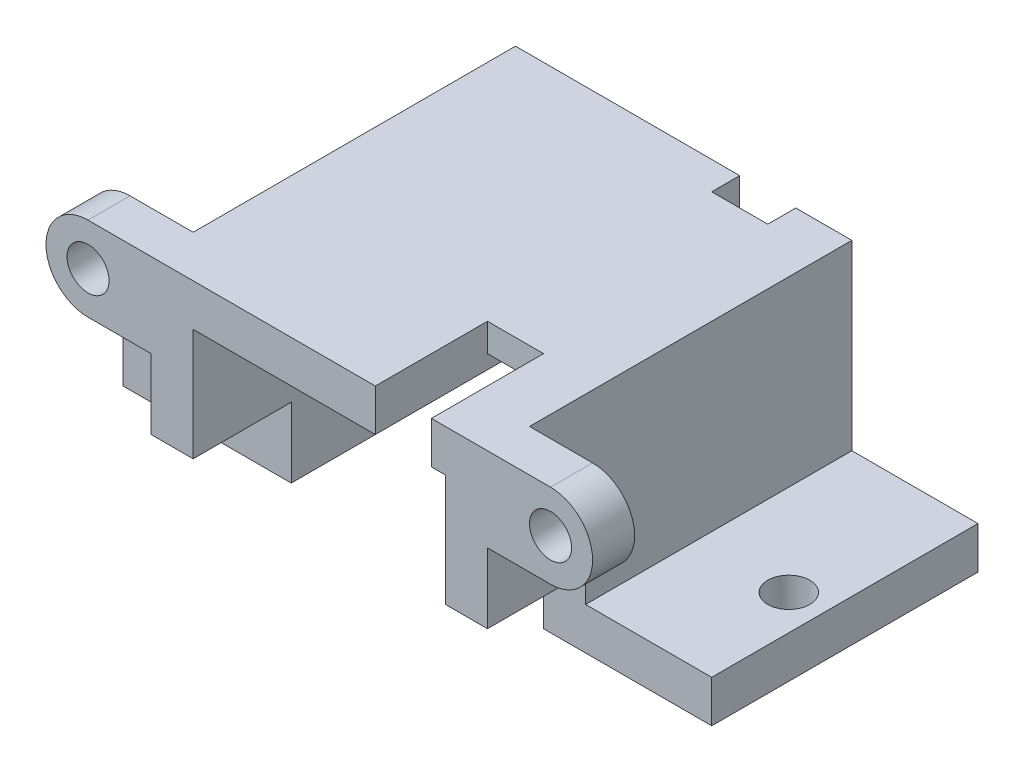
from build123d import *

# Parameters (mm, degrees)
EXTRU_MINCE1_DEPTH      = 13
EXTRUSION1_DEPTH        = 3
ESQUISSE3_R             = 1.5
ENL_V_MAT_EXTRU_1_DEPTH = 3
ENL_V_MAT_EXTRU_2_REACH = 18
ESQUISSE4_W             = 4
ESQUISSE4_H             = 8
ESQUISSE4_H_2           = 2
ESQUISSE6_W             = 7
ESQUISSE6_H             = 5
ENL_V_MAT_EXTRU_4_DEPTH = 42
ESQUISSE7_R             = 1.5
ENL_V_MAT_EXTRU_5_DEPTH = 3
ESQUISSE8_W             = 4
ESQUISSE8_H             = 16
ENL_V_MAT_EXTRU_6_DEPTH = 1


with BuildPart() as part:
    # Esquisse1 → Extru.-Mince1 (new body, symmetric)
    with BuildSketch(Plane.XY):
        Polygon((-21, 0), (-9, 0), (-9, 13), (9, 13), (9, 0), (21, 0), (21, 3), (12, 3), (12, 16), (-12, 16), (-12, 3), (-21, 3), align=None)
    extrude(amount=EXTRU_MINCE1_DEPTH, both=True)

    # Esquisse2 → Extrusion1 (add)
    with BuildSketch(Plane.XY.offset(13)):
        with BuildLine():
            Line((-12, 16), (-16.5, 16))
            ThreePointArc((-16.5, 16), (-19.5, 13), (-16.5, 10))
            Line((-16.5, 10), (-12, 10))
            Line((-12, 10), (-12, 16))
        make_face()
    extrusion1 = extrude(amount=-EXTRUSION1_DEPTH)

    # Esquisse3 → Enlèv. mat.-Extru.1 (cut)
    with BuildSketch(Plane.XY.offset(13)):
        with Locations((-16.5, 13)):
            Circle(ESQUISSE3_R)
    enl_v_mat_extru_1 = extrude(amount=-ENL_V_MAT_EXTRU_1_DEPTH, mode=Mode.SUBTRACT)

    # Symétrie1: Extrusion1, Enlèv. mat.-Extru.1 across plane
    add(extrusion1.mirror(Plane(origin=(0, 0, 0), x_dir=(0, 0, 1), z_dir=(1, 0, 0))))
    add(enl_v_mat_extru_1.mirror(Plane(origin=(0, 0, 0), x_dir=(0, 0, 1), z_dir=(1, 0, 0))), mode=Mode.SUBTRACT)

    # Esquisse4 → Enlèv. mat.-Extru.2 (cut, up to next)
    with BuildSketch(Plane(origin=(0, 16, 0), x_dir=(1, 0, 0), z_dir=(0, 1, 0)), mode=Mode.PRIVATE) as enl_v_mat_extru_2_sk1:
        with Locations((6, -9)):
            Rectangle(ESQUISSE4_W, ESQUISSE4_H)
    enl_v_mat_extru_2_tool1 = extrude(enl_v_mat_extru_2_sk1.sketch, amount=-ENL_V_MAT_EXTRU_2_REACH, mode=Mode.PRIVATE) & part.part
    add(enl_v_mat_extru_2_tool1.solids().sort_by_distance((6, 16, 9))[0], mode=Mode.SUBTRACT)
    # Esquisse4 → Enlèv. mat.-Extru.2 (cut, up to next)
    with BuildSketch(Plane(origin=(0, 16, 0), x_dir=(1, 0, 0), z_dir=(0, 1, 0)), mode=Mode.PRIVATE) as enl_v_mat_extru_2_sk2:
        with Locations((6, 12)):
            Rectangle(ESQUISSE4_W, ESQUISSE4_H_2)
    enl_v_mat_extru_2_tool2 = extrude(enl_v_mat_extru_2_sk2.sketch, amount=-ENL_V_MAT_EXTRU_2_REACH, mode=Mode.PRIVATE) & part.part
    add(enl_v_mat_extru_2_tool2.solids().sort_by_distance((6, 16, -12))[0], mode=Mode.SUBTRACT)

    # Esquisse6 → Enlèv. mat.-Extru.4 (cut)
    with BuildSketch(Plane(origin=(21, 0, 0), x_dir=(0, 0, -1), z_dir=(1, 0, 0))):
        with Locations((-9.5, 2.5)):
            Rectangle(ESQUISSE6_W, ESQUISSE6_H)
    extrude(amount=-ENL_V_MAT_EXTRU_4_DEPTH, mode=Mode.SUBTRACT)

    # Esquisse7 → Enlèv. mat.-Extru.5 (cut)
    with BuildSketch(Plane(origin=(0, 3, 0), x_dir=(1, 0, 0), z_dir=(0, 1, 0))):
        with Locations(Location((18.5, 2, 0), (0, 0, 270))):  # turned: the seam where the file's is
            Circle(ESQUISSE7_R)
    enl_v_mat_extru_5 = extrude(amount=-ENL_V_MAT_EXTRU_5_DEPTH, mode=Mode.SUBTRACT)

    # Symétrie2: Enlèv. mat.-Extru.5 across plane
    add(enl_v_mat_extru_5.mirror(Plane(origin=(0, 0, 0), x_dir=(0, 0, 1), z_dir=(1, 0, 0))), mode=Mode.SUBTRACT)

    # Esquisse8 → Enlèv. mat.-Extru.6 (cut)
    with BuildSketch(Plane.XZ.offset(-13)):
        with Locations((6, -3)):
            Rectangle(ESQUISSE8_W, ESQUISSE8_H)
    extrude(amount=-ENL_V_MAT_EXTRU_6_DEPTH, mode=Mode.SUBTRACT)


solid = part.part
